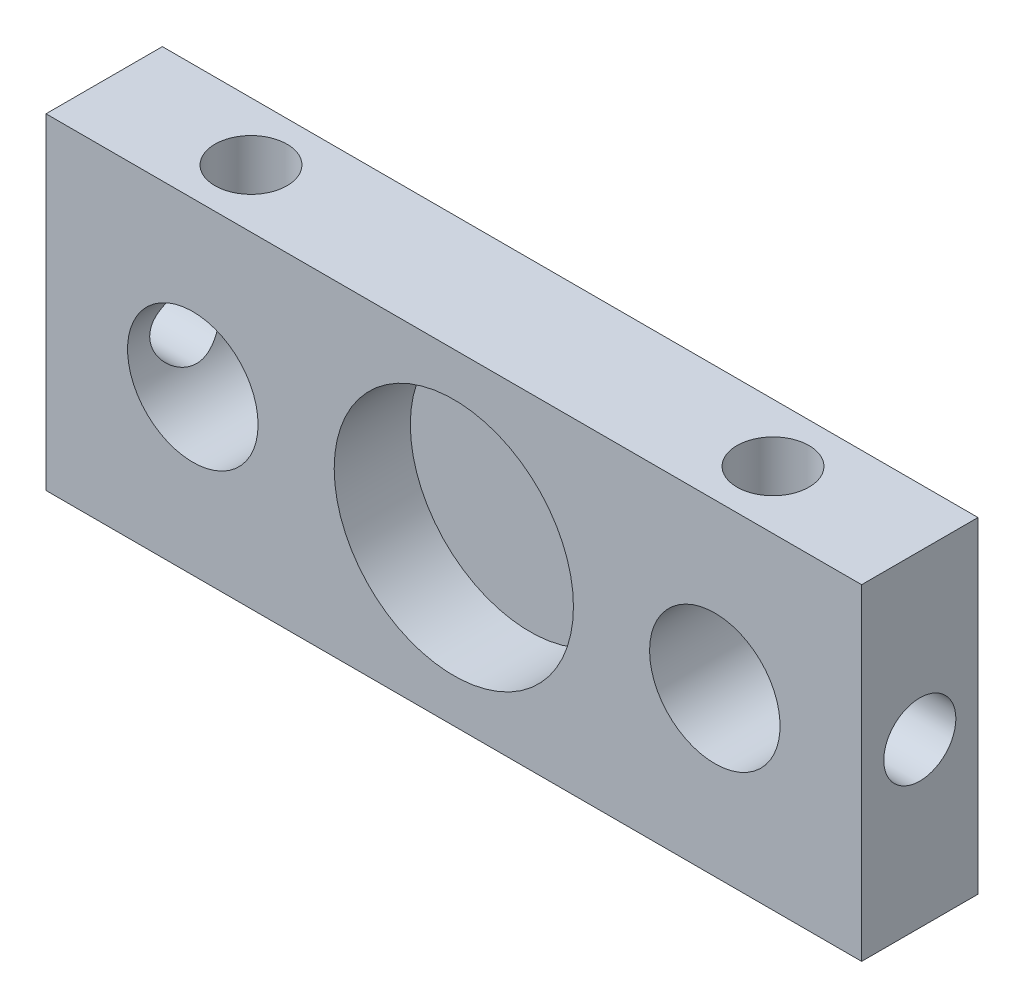
from build123d import *

# Parameters (mm, degrees)
ESBO_O1_W                                   = 75
ESBO_O1_H                                   = 30
RESSALTO_EXTRUS_O1_DEPTH                    = 10.7
ESBO_O2_R                                   = 6
CORTE_EXTRUS_O1_DEPTH                       = 10
ESBO_O7_R                                   = 11
CORTE_EXTRUS_O6_DEPTH                       = 7
FURO_ROSCADO_PARA_CONDU_TE_DE_1_4_281_D     = 6.6294
FURO_ROSCADO_PARA_CONDU_TE_DE_1_4_281_DEPTH = 15
FURO_ROSCADO_PARA_CONDU_TE_DE_1_4_281_TIP   = 1.991672694
FURO_ROSCADO_PARA_CONDU_TE_DE_1_4_282_D     = 6.6294
FURO_ROSCADO_PARA_CONDU_TE_DE_1_4_282_DEPTH = 14.96
FURO_ROSCADO_PARA_CONDU_TE_DE_1_4_282_TIP   = 1.991672694
FURO_ROSCADO_PARA_CONDU_TE_DE_1_4_283_D     = 6.6294
FURO_ROSCADO_PARA_CONDU_TE_DE_1_4_283_DEPTH = 15
FURO_ROSCADO_PARA_CONDU_TE_DE_1_4_283_TIP   = 1.991672694
FURO_ROSCADO_PARA_CONDU_TE_DE_1_4_284_D     = 6.6294
FURO_ROSCADO_PARA_CONDU_TE_DE_1_4_284_DEPTH = 12
FURO_ROSCADO_PARA_CONDU_TE_DE_1_4_284_TIP   = 1.991672694


with BuildPart() as part:
    # Esboço1 → Ressalto-extrusão1 (new body)
    with BuildSketch(Plane.XY):
        Rectangle(ESBO_O1_W, ESBO_O1_H)
    extrude(amount=RESSALTO_EXTRUS_O1_DEPTH)

    # Esboço2 → Corte-extrusão1 (cut)
    with BuildSketch(Plane.XY.offset(10.7)):
        with Locations((-24, 0)):
            Circle(ESBO_O2_R)
        with Locations((24, 0)):
            Circle(ESBO_O2_R)
    extrude(amount=-CORTE_EXTRUS_O1_DEPTH, mode=Mode.SUBTRACT)

    # Esboço7 → Corte-extrusão6 (cut)
    with BuildSketch(Plane.XY.offset(10.7)):
        Circle(ESBO_O7_R)
    extrude(amount=-CORTE_EXTRUS_O6_DEPTH, mode=Mode.SUBTRACT)

    # Furo roscado para conduíte de 1/4-281
    with Locations(Plane(origin=(0, 15, 0), x_dir=(1, 0, 0), z_dir=(0, 1, 0))):
        with Locations((-24, -5.35), (24, -5.35)):
            Hole(FURO_ROSCADO_PARA_CONDU_TE_DE_1_4_281_D / 2, depth=FURO_ROSCADO_PARA_CONDU_TE_DE_1_4_281_DEPTH)
            with Locations((0, 0, -(FURO_ROSCADO_PARA_CONDU_TE_DE_1_4_281_DEPTH + FURO_ROSCADO_PARA_CONDU_TE_DE_1_4_281_TIP / 2))):  # 118° drill point
                Cone(0, FURO_ROSCADO_PARA_CONDU_TE_DE_1_4_281_D / 2, FURO_ROSCADO_PARA_CONDU_TE_DE_1_4_281_TIP, mode=Mode.SUBTRACT)

    # Furo roscado para conduíte de 1/4-282
    with Locations(Plane.ZY.offset(37.5)):
        with Locations((5.35, 0)):
            Hole(FURO_ROSCADO_PARA_CONDU_TE_DE_1_4_282_D / 2, depth=FURO_ROSCADO_PARA_CONDU_TE_DE_1_4_282_DEPTH)
            with Locations((0, 0, -(FURO_ROSCADO_PARA_CONDU_TE_DE_1_4_282_DEPTH + FURO_ROSCADO_PARA_CONDU_TE_DE_1_4_282_TIP / 2))):  # 118° drill point
                Cone(0, FURO_ROSCADO_PARA_CONDU_TE_DE_1_4_282_D / 2, FURO_ROSCADO_PARA_CONDU_TE_DE_1_4_282_TIP, mode=Mode.SUBTRACT)

    # Furo roscado para conduíte de 1/4-283
    with Locations(Plane(origin=(37.5, 0, 0), x_dir=(0, 0, -1), z_dir=(1, 0, 0))):
        with Locations((-5.35, 0)):
            Hole(FURO_ROSCADO_PARA_CONDU_TE_DE_1_4_283_D / 2, depth=FURO_ROSCADO_PARA_CONDU_TE_DE_1_4_283_DEPTH)
            with Locations((0, 0, -(FURO_ROSCADO_PARA_CONDU_TE_DE_1_4_283_DEPTH + FURO_ROSCADO_PARA_CONDU_TE_DE_1_4_283_TIP / 2))):  # 118° drill point
                Cone(0, FURO_ROSCADO_PARA_CONDU_TE_DE_1_4_283_D / 2, FURO_ROSCADO_PARA_CONDU_TE_DE_1_4_283_TIP, mode=Mode.SUBTRACT)

    # Furo roscado para conduíte de 1/4-284
    with Locations(Plane(origin=(0, -15, 0), x_dir=(-1, 0, 0), z_dir=(0, -1, 0))):
        with Locations((15, -5.35), (-15, -5.35)):
            Hole(FURO_ROSCADO_PARA_CONDU_TE_DE_1_4_284_D / 2, depth=FURO_ROSCADO_PARA_CONDU_TE_DE_1_4_284_DEPTH)
            with Locations((0, 0, -(FURO_ROSCADO_PARA_CONDU_TE_DE_1_4_284_DEPTH + FURO_ROSCADO_PARA_CONDU_TE_DE_1_4_284_TIP / 2))):  # 118° drill point
                Cone(0, FURO_ROSCADO_PARA_CONDU_TE_DE_1_4_284_D / 2, FURO_ROSCADO_PARA_CONDU_TE_DE_1_4_284_TIP, mode=Mode.SUBTRACT)


solid = part.part
